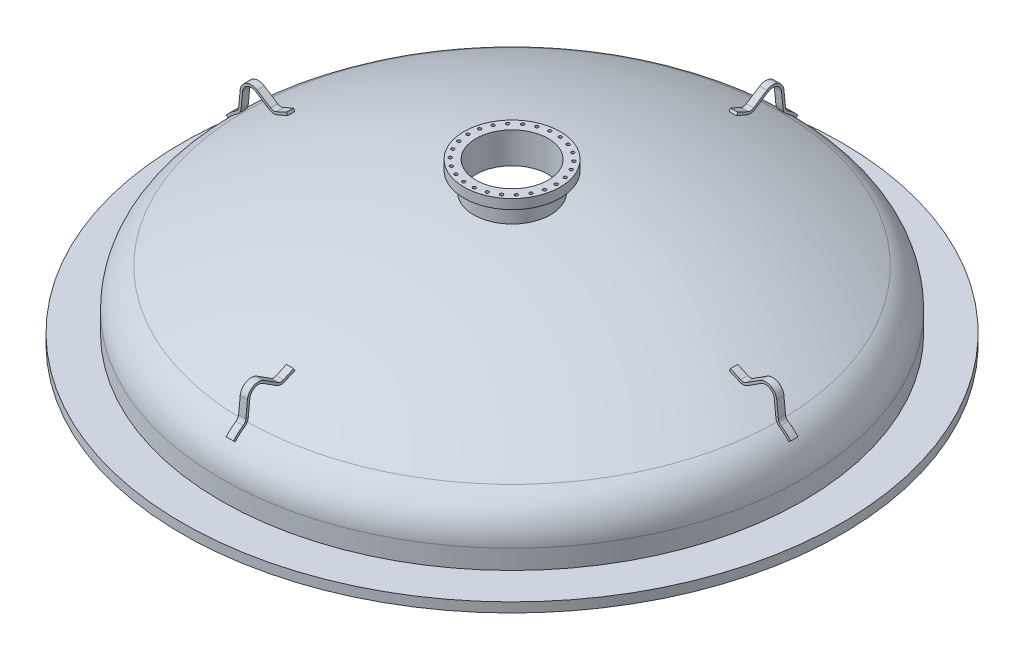
from build123d import *

# Parameters (mm, degrees)
SKETCH10_R          = 95.25
CUT_EXTRUDE4_DEPTH  = 423.101510846
SKETCH13_R          = 4.2164
CUT_EXTRUDE7_DEPTH  = 25.4
CIRPATTERN1_COUNT   = 26
BOSS_EXTRUDE1_DEPTH = 9.525
CIRPATTERN22_COUNT  = 4


with BuildPart() as part:
    # Sketch2 → Revolve6 (revolve)
    with BuildSketch(Plane.ZY):
        with BuildLine():
            Line((-762, 0), (-762, 76.2))
            ThreePointArc((-762, 76.2), (-746.146387828, 132.632796575), (-703.224203775, 172.553764303))
            ThreePointArc((-703.224203775, 172.553764303), (-361.781052845, 299.706397644), (0, 342.9))
            Line((0, 342.9), (0, 349.25))
            ThreePointArc((0, 349.25), (-363.276015874, 305.877911683), (-706.130088915, 178.199854238))
            ThreePointArc((-706.130088915, 178.199854238), (-751.567405751, 135.939617508), (-768.35, 76.2))
            Line((-768.35, 76.2), (-768.35, 25.4))
            Line((-768.35, 25.4), (-869.95, 25.4))
            Line((-869.95, 25.4), (-869.95, 0))
            Line((-869.95, 0), (-762, 0))
        make_face()
    revolve(axis=Axis((0, 0, 0), (0, 1, 0)))

    # Sketch3 → Revolve7 (revolve)
    with BuildSketch(Plane(origin=(0, 0, 0), x_dir=(0, 0, -1), z_dir=(1, 0, 0))):
        with BuildLine():
            Line((101.6, 345.901510846), (101.6, 396.701510846))
            Line((101.6, 396.701510846), (127, 396.701510846))
            Line((127, 396.701510846), (127, 422.101510846))
            Line((127, 422.101510846), (0, 422.101510846))
            Line((0, 422.101510846), (0, 349.25))
            ThreePointArc((0, 349.25), (50.827582029, 348.412650514), (101.6, 345.901510846))
        make_face()
    revolve(axis=Axis((0, -136.02863292, 0), (0, 1, 0)))

    # Sketch10 → Cut-Extrude4 (cut, through all)
    with BuildSketch(Plane(origin=(0, 422.101510846, 0), x_dir=(-1, 0, 0), z_dir=(0, 1, 0))):
        with Locations(Location((0, 0, 0), (0, 0, 270))):  # turned: the seam where the file's is
            Circle(SKETCH10_R)
    extrude(amount=-CUT_EXTRUDE4_DEPTH, mode=Mode.SUBTRACT)

    # Sketch13 → Cut-Extrude7 (cut)
    with BuildSketch(Plane(origin=(0, 422.101510846, 0), x_dir=(-1, 0, 0), z_dir=(0, 1, 0))):
        with Locations(Location((15.068335208, -114.455369132, 0), (0, 0, 90))):  # turned: the seam where the file's is
            Circle(SKETCH13_R)
    cut_extrude7 = extrude(amount=-CUT_EXTRUDE7_DEPTH, mode=Mode.SUBTRACT)

    # CirPattern1: Cut-Extrude7 ×26 about axis
    cirpattern1_axis = Axis((0, 0, 0), (0, 1, 0))
    for i in range(1, CIRPATTERN1_COUNT):
        add(cut_extrude7.rotate(cirpattern1_axis, i * 360 / CIRPATTERN1_COUNT), mode=Mode.SUBTRACT)


with BuildPart() as body_2:
    # Sketch14 → Boss-Extrude1 (new body, symmetric)
    with BuildSketch(Plane(origin=(0, 0, 0), x_dir=(0, 0, -1), z_dir=(1, 0, 0))):
        with BuildLine():
            ThreePointArc((701.771475299, 230.845762836), (688.96145015, 249.179850503), (666.635850873, 247.837043046))
            Line((666.635850873, 247.837043046), (631.197371994, 225.092934291))
            ThreePointArc((631.197371994, 225.092934291), (621.012251078, 221.646760251), (610.40135459, 223.385058069))
            ThreePointArc((610.40135459, 223.385058069), (596.652944202, 229.227957095), (582.848612837, 234.937483589))
            Line((582.848612837, 234.937483589), (586.107203917, 241.474705604))
            ThreePointArc((586.107203917, 241.474705604), (599.539398268, 235.409646563), (612.913294321, 229.217095345))
            ThreePointArc((612.913294321, 229.217095345), (620.492506098, 227.975454047), (627.767592467, 230.437006932))
            Line((627.767592467, 230.437006932), (663.206071346, 253.181115687))
            ThreePointArc((663.206071346, 253.181115687), (691.725966245, 254.896488568), (708.09016621, 231.475560562))
            Line((708.09016621, 231.475560562), (712.266582761, 189.574035374))
            ThreePointArc((712.266582761, 189.574035374), (714.510936265, 182.881196981), (719.435009178, 177.823063496))
            ThreePointArc((719.435009178, 177.823063496), (733.070636578, 167.560986655), (745.127825573, 155.483538695))
            Line((745.127825573, 155.483538695), (740.328902649, 151.325072779))
            ThreePointArc((740.328902649, 151.325072779), (728.904119957, 162.769051844), (715.983688834, 172.492877019))
            ThreePointArc((715.983688834, 172.492877019), (709.089986756, 179.574263897), (705.947891851, 188.944237647))
            Line((705.947891851, 188.944237647), (701.771475299, 230.845762836))
        make_face()
    extrude(amount=BOSS_EXTRUDE1_DEPTH, both=True)


with BuildPart() as cirpattern22_1:
    # CirPattern22: pattern copy
    add(body_2.part.rotate(Axis((0, 0, 0), (0, 1, 0)), 1 * 360 / CIRPATTERN22_COUNT))


with BuildPart() as cirpattern22_2:
    # CirPattern22: pattern copy
    add(body_2.part.rotate(Axis((0, 0, 0), (0, 1, 0)), 2 * 360 / CIRPATTERN22_COUNT))


with BuildPart() as cirpattern22_3:
    # CirPattern22: pattern copy
    add(body_2.part.rotate(Axis((0, 0, 0), (0, 1, 0)), 3 * 360 / CIRPATTERN22_COUNT))


solid = Compound([part.part, body_2.part, cirpattern22_1.part, cirpattern22_2.part, cirpattern22_3.part])
